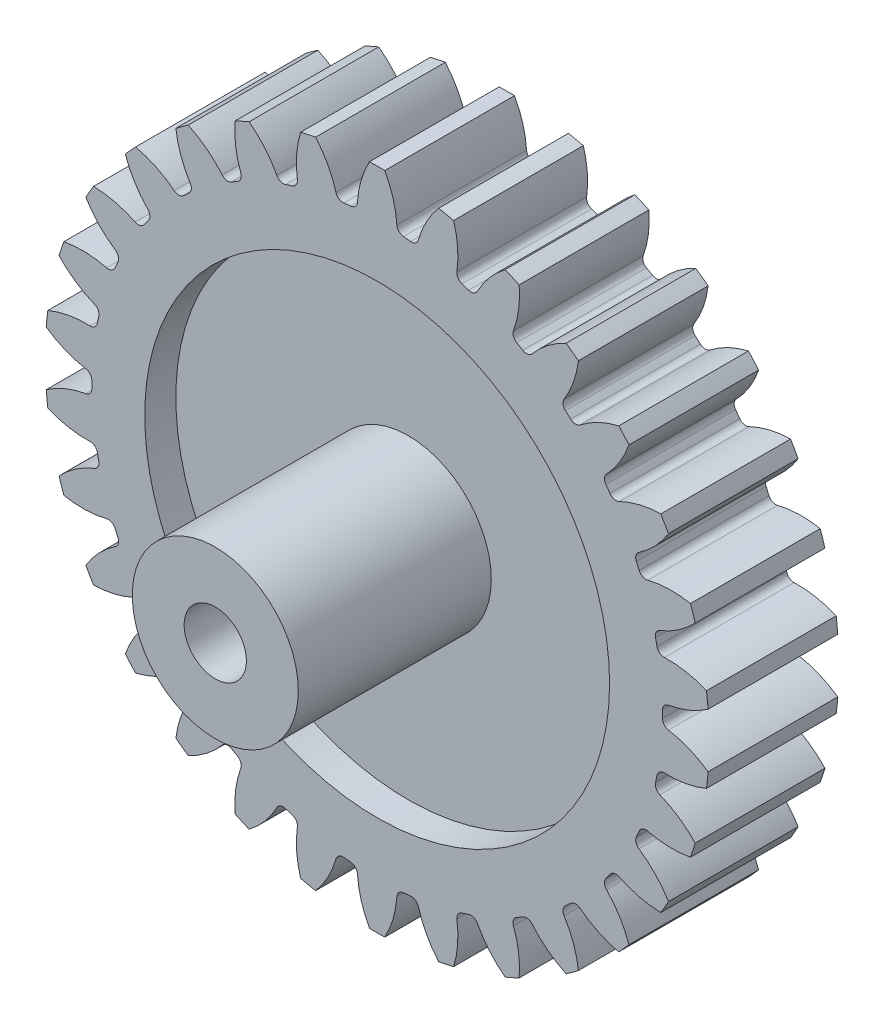
from build123d import *

# Parameters (mm, degrees)
BOSS_EXTRU_1_DEPTH                 = 6.25
CONG_1_R                           = 0.35
R_P_TITION_CIRCULAIRE4_COUNT       = 30
CONG_1_OF_R_P_TITION_CIRCULAIRE4_R = 0.35
ESQUISSE5_R                        = 11.2
ENL_V_MAT_EXTRU_1_DEPTH            = 1.5
ESQUISSE6_R                        = 4
BOSS_EXTRU_2_DEPTH                 = 9.3
ESQUISSE7_R                        = 1.5
ENL_V_MAT_EXTRU_2_DEPTH            = 15.0500001
ESQUISSE8_R                        = 11.2
ESQUISSE8_R_2                      = 4
ENL_V_MAT_EXTRU_3_DEPTH            = 1.5


with BuildPart() as part:
    # Esquisse3 → Boss.-Extru.1 (new body)
    with BuildSketch(Plane.XY):
        with BuildLine():
            Line((-2.815973283, 13.114323603), (-1.378706913, -0.560352459))
            Line((-1.378706913, -0.560352459), (0.058559457, 13.114323603))
            ThreePointArc((0.058559457, 13.114323603), (-0.179048304, 13.13721372), (-0.417017629, 13.155975538))
            ThreePointArc((-0.417017629, 13.155975538), (-0.570386975, 14.332927738), (-1.010039564, 15.435399615))
            ThreePointArc((-1.010039564, 15.435399615), (-1.378706913, 15.439647541), (-1.747374262, 15.435399615))
            ThreePointArc((-1.747374262, 15.435399615), (-2.187026852, 14.332927738), (-2.340396198, 13.155975538))
            ThreePointArc((-2.340396198, 13.155975538), (-2.578365523, 13.13721372), (-2.815973283, 13.114323603))
        make_face()
    boss_extru_1 = extrude(amount=BOSS_EXTRU_1_DEPTH)

    # Cong_1
    cong_1_edges = [part.edges().sort_by_distance(p)[0] for p in [
        (-2.340396198, 13.155975538, 3.125),
        (-0.417017629, 13.155975538, 3.125),
    ]]
    fillet(cong_1_edges, radius=CONG_1_R)

    # R_p_tition circulaire4: Boss.-Extru.1 ×30 about axis
    r_p_tition_circulaire4_axis = Axis((-1.378706913, -0.560352459, 0), (0, 0, 1))
    for i in range(1, R_P_TITION_CIRCULAIRE4_COUNT):
        add(boss_extru_1.rotate(r_p_tition_circulaire4_axis, i * 360 / R_P_TITION_CIRCULAIRE4_COUNT))

    # Cong_1 of R_p_tition circulaire4
    cong_1_of_r_p_tition_circulaire4_edges = [part.edges().sort_by_distance(p)[0] for p in [
        (-5.171165925, 12.656294417, 3.125),
        (-3.289817792, 13.056187308, 3.125),
        (-7.836186996, 11.578982407, 3.125),
        (-6.07909324, 12.36129095, 3.125),
        (-10.2189852, 9.971123213, 3.125),
        (-8.662939251, 11.10165677, 3.125),
        (-12.215420823, 7.902987995, 3.125),
        (-10.928429354, 9.332336827, 3.125),
        (-13.738240047, 5.464964189, 3.125),
        (-12.776550763, 7.130658891, 3.125),
        (-14.720888367, 2.763605132, 3.125),
        (-14.126531702, 4.592846854, 3.125),
        (-15.120419333, -0.083026822, 3.125),
        (-14.919371527, 1.829815279, 3.125),
        (-14.919371527, -2.950520196, 3.125),
        (-15.120419333, -1.037678096, 3.125),
        (-14.126531702, -5.713551771, 3.125),
        (-14.720888367, -3.884310049, 3.125),
        (-12.776550763, -8.251363808, 3.125),
        (-13.738240047, -6.585669106, 3.125),
        (-10.928429354, -10.453041744, 3.125),
        (-12.215420823, -9.023692913, 3.125),
        (-8.662939251, -12.222361687, 3.125),
        (-10.2189852, -11.09182813, 3.125),
        (-6.07909324, -13.481995867, 3.125),
        (-7.836186996, -12.699687324, 3.125),
        (-3.289817792, -14.176892225, 3.125),
        (-5.171165925, -13.776999334, 3.125),
        (-0.417017629, -14.276680456, 3.125),
        (-2.340396198, -14.276680456, 3.125),
        (2.413752099, -13.776999334, 3.125),
        (0.532403966, -14.176892225, 3.125),
        (5.078773169, -12.699687324, 3.125),
        (3.321679414, -13.481995867, 3.125),
        (7.461571374, -11.09182813, 3.125),
        (5.905525424, -12.222361687, 3.125),
        (9.458006996, -9.023692913, 3.125),
        (8.171015528, -10.453041744, 3.125),
        (10.980826221, -6.585669106, 3.125),
        (10.019136937, -8.251363808, 3.125),
        (11.96347454, -3.884310049, 3.125),
        (11.369117876, -5.713551771, 3.125),
        (12.363005507, -1.037678096, 3.125),
        (12.161957701, -2.950520196, 3.125),
        (12.161957701, 1.829815279, 3.125),
        (12.363005507, -0.083026822, 3.125),
        (11.369117876, 4.592846854, 3.125),
        (11.96347454, 2.763605132, 3.125),
        (10.019136937, 7.130658891, 3.125),
        (10.980826221, 5.464964189, 3.125),
        (8.171015528, 9.332336827, 3.125),
        (9.458006996, 7.902987995, 3.125),
        (5.905525424, 11.10165677, 3.125),
        (7.461571374, 9.971123213, 3.125),
        (3.321679414, 12.36129095, 3.125),
        (5.078773169, 11.578982407, 3.125),
        (0.532403966, 13.056187308, 3.125),
        (2.413752099, 12.656294417, 3.125),
    ]]
    fillet(cong_1_of_r_p_tition_circulaire4_edges, radius=CONG_1_OF_R_P_TITION_CIRCULAIRE4_R)

    # Esquisse5 → Enl_v. mat.-Extru.1 (cut)
    with BuildSketch(Plane.XY.offset(6.25)):
        with Locations((-1.378706913, -0.560352459)):
            Circle(ESQUISSE5_R)
    extrude(amount=-ENL_V_MAT_EXTRU_1_DEPTH, mode=Mode.SUBTRACT)

    # Esquisse6 → Boss.-Extru.2 (add)
    with BuildSketch(Plane.XY.offset(4.75)):
        with Locations((-1.378706913, -0.560352459)):
            Circle(ESQUISSE6_R)
    extrude(amount=BOSS_EXTRU_2_DEPTH)

    # Esquisse7 → Enl_v. mat.-Extru.2 (cut, through all)
    with BuildSketch(Plane.XY.offset(14.05)):
        with Locations((-1.378706913, -0.560352459)):
            Circle(ESQUISSE7_R)
    extrude(amount=-ENL_V_MAT_EXTRU_2_DEPTH, mode=Mode.SUBTRACT)

    # Esquisse8 → Enl_v. mat.-Extru.3 (cut)
    with BuildSketch(Plane(origin=(0, 0, 0), x_dir=(-1, 0, 0), z_dir=(0, 0, -1))):
        with Locations(Location((1.378706913, -0.560352459, 0), (0, 0, 180))):  # turned: the seam where the file's is
            Circle(ESQUISSE8_R)
        with Locations(Location((1.378706913, -0.560352459, 0), (0, 0, 180))):  # turned: the seam where the file's is
            Circle(ESQUISSE8_R_2, mode=Mode.SUBTRACT)
    extrude(amount=-ENL_V_MAT_EXTRU_3_DEPTH, mode=Mode.SUBTRACT)


solid = part.part
